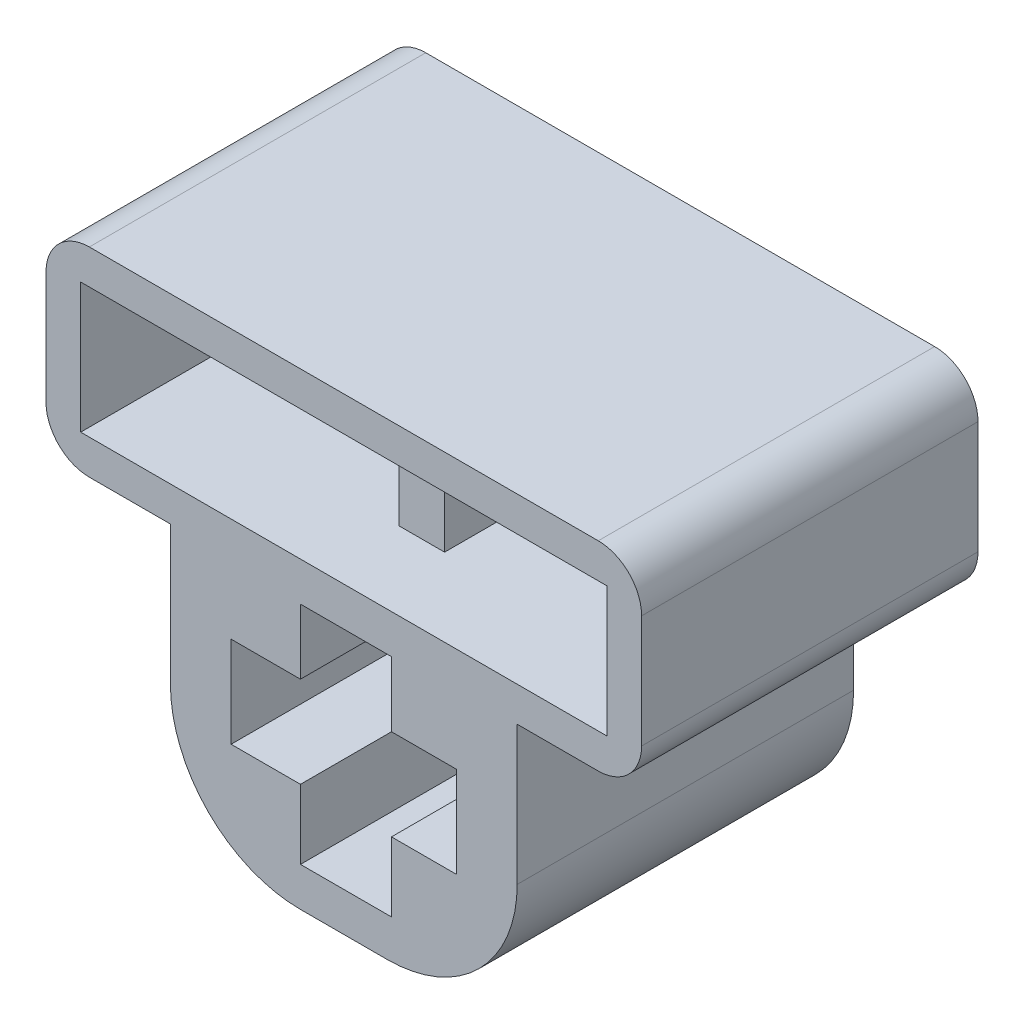
from build123d import *

# Parameters (mm, degrees)
SKETCH1_W           = 8
SKETCH1_H           = 7
BOSS_EXTRUDE1_DEPTH = 7.76
CUT_EXTRUDE3_DEPTH  = 8.76
SKETCH7_W           = 7.76
SKETCH7_H           = 0.8
BOSS_EXTRUDE2_DEPTH = 2.87
SKETCH9_W           = 7.76
SKETCH9_H           = 0.8
BOSS_EXTRUDE3_DEPTH = 2.87
SKETCH10_W          = 0.8
SKETCH10_H          = 7.76
BOSS_EXTRUDE4_DEPTH = 3
SKETCH11_W          = 0.8
SKETCH11_H          = 7.76
BOSS_EXTRUDE5_DEPTH = 3
SKETCH12_W          = 13.74
SKETCH12_H          = 7.76
BOSS_EXTRUDE6_DEPTH = 0.8
BOSS_EXTRUDE7_REACH = 5.8
FILLET4_R           = 1
FILLET5_R           = 1
FILLET6_R           = 1
FILLET7_R           = 1
FILLET8_R           = 3
FILLET9_R           = 3


with BuildPart() as part:
    # Sketch1 → Boss-Extrude1 (new body)
    with BuildSketch(Plane.XY):
        Rectangle(SKETCH1_W, SKETCH1_H)
    extrude(amount=BOSS_EXTRUDE1_DEPTH)

    # Sketch6 → Cut-Extrude3 (cut, through all)
    with BuildSketch(Plane.XY.offset(7.76)):
        Polygon((1.1, -1), (2.6, -1), (2.6, 1.1), (1.1, 1.1), (1.1, 2.6), (-1, 2.6), (-1, 1.1), (-2.6, 1.1), (-2.6, -1), (-1, -1), (-1, -2.6), (1.1, -2.6), align=None)
    extrude(amount=-CUT_EXTRUDE3_DEPTH, mode=Mode.SUBTRACT)

    # Sketch7 → Boss-Extrude2 (add)
    with BuildSketch(Plane.ZY.offset(4)):
        with Locations((3.88, 3.1)):
            Rectangle(SKETCH7_W, SKETCH7_H)
    extrude(amount=BOSS_EXTRUDE2_DEPTH)

    # Sketch9 → Boss-Extrude3 (add)
    with BuildSketch(Plane(origin=(4, 0, 0), x_dir=(0, 0, -1), z_dir=(1, 0, 0))):
        with Locations((-3.88, 3.1)):
            Rectangle(SKETCH9_W, SKETCH9_H)
    extrude(amount=BOSS_EXTRUDE3_DEPTH)

    # Sketch10 → Boss-Extrude4 (add)
    with BuildSketch(Plane(origin=(0, 3.5, 0), x_dir=(1, 0, 0), z_dir=(0, 1, 0))):
        with Locations((6.47, -3.88)):
            Rectangle(SKETCH10_W, SKETCH10_H)
    extrude(amount=BOSS_EXTRUDE4_DEPTH)

    # Sketch11 → Boss-Extrude5 (add)
    with BuildSketch(Plane(origin=(0, 3.5, 0), x_dir=(1, 0, 0), z_dir=(0, 1, 0))):
        with Locations((-6.47, -3.88)):
            Rectangle(SKETCH11_W, SKETCH11_H)
    extrude(amount=BOSS_EXTRUDE5_DEPTH)

    # Sketch12 → Boss-Extrude6 (add)
    with BuildSketch(Plane(origin=(0, 6.5, 0), x_dir=(1, 0, 0), z_dir=(0, 1, 0))):
        with Locations((0, -3.88)):
            Rectangle(SKETCH12_W, SKETCH12_H)
    extrude(amount=BOSS_EXTRUDE6_DEPTH)

    # Sketch14 → Boss-Extrude7 (add, up to next)
    with BuildSketch(Plane(origin=(0, 3.5, 0), x_dir=(1, 0, 0), z_dir=(0, 1, 0)), mode=Mode.PRIVATE) as boss_extrude7_sk1:
        Polygon((0.525000003, -0.003794521), (-0.524999997, -0.003794521), (-0.524994746, -5.96), (0.525005254, -5.96), align=None)
    boss_extrude7_tool1 = extrude(boss_extrude7_sk1.sketch, amount=BOSS_EXTRUDE7_REACH, mode=Mode.PRIVATE) - part.part
    add(boss_extrude7_tool1.solids().sort_by_distance((3e-06, 3.5, 2.981897))[0])

    # Fillet4
    fillet4_edges = [part.edges().sort_by_distance(p)[0] for p in [
        (-6.87, 7.3, 3.88),
    ]]
    fillet(fillet4_edges, radius=FILLET4_R)

    # Fillet5
    fillet5_edges = [part.edges().sort_by_distance(p)[0] for p in [
        (6.87, 7.3, 3.88),
    ]]
    fillet(fillet5_edges, radius=FILLET5_R)

    # Fillet6
    fillet6_edges = [part.edges().sort_by_distance(p)[0] for p in [
        (-6.87, 2.7, 3.88),
    ]]
    fillet(fillet6_edges, radius=FILLET6_R)

    # Fillet7
    fillet7_edges = [part.edges().sort_by_distance(p)[0] for p in [
        (6.87, 2.7, 3.88),
    ]]
    fillet(fillet7_edges, radius=FILLET7_R)

    # Fillet8
    fillet8_edges = [part.edges().sort_by_distance(p)[0] for p in [
        (4, -3.5, 3.88),
    ]]
    fillet(fillet8_edges, radius=FILLET8_R)

    # Fillet9
    fillet9_edges = [part.edges().sort_by_distance(p)[0] for p in [
        (-4, -3.5, 3.88),
    ]]
    fillet(fillet9_edges, radius=FILLET9_R)


solid = part.part
